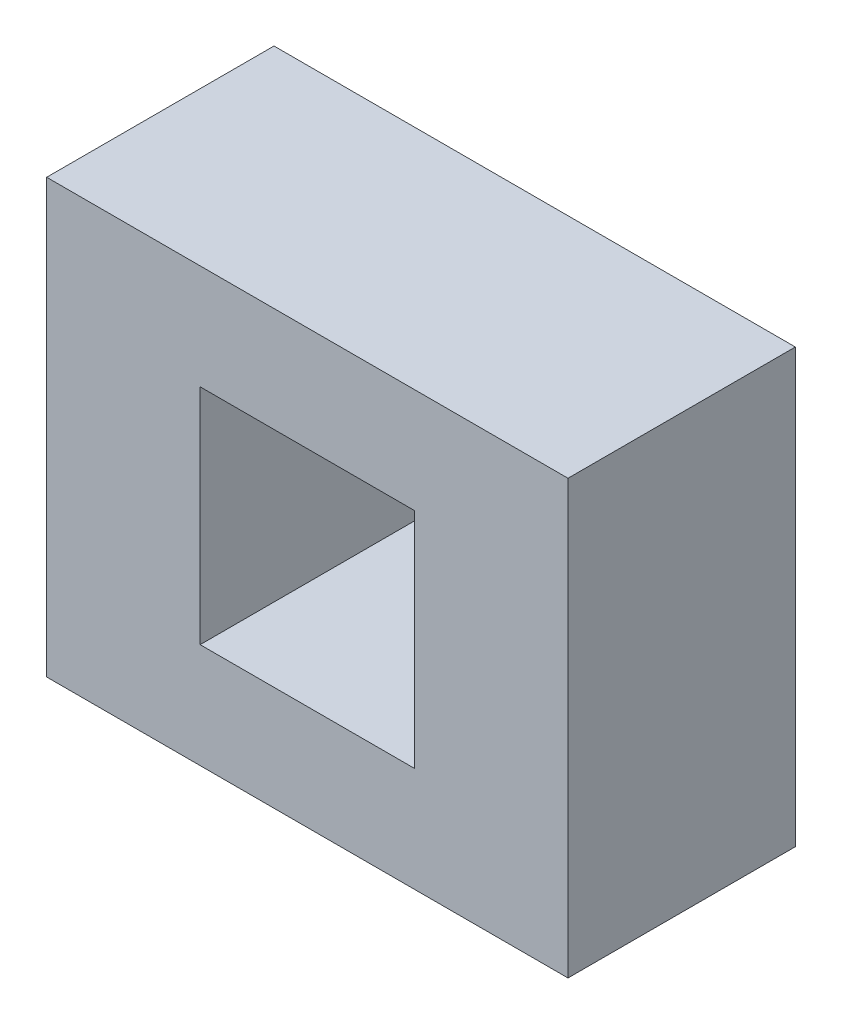
from build123d import *

# Parameters (mm, degrees)
SKETCH1_W           = 114.660795688
SKETCH1_H           = 95.193464334
SKETCH1_W_2         = 47.150233742
SKETCH1_H_2         = 49.114826814
BOSS_EXTRUDE1_DEPTH = 50


with BuildPart() as part:
    # Sketch1 → Boss-Extrude1 (new body)
    with BuildSketch(Plane.XY):
        Rectangle(SKETCH1_W, SKETCH1_H)
        Rectangle(SKETCH1_W_2, SKETCH1_H_2, mode=Mode.SUBTRACT)
    extrude(amount=BOSS_EXTRUDE1_DEPTH)


solid = part.part
